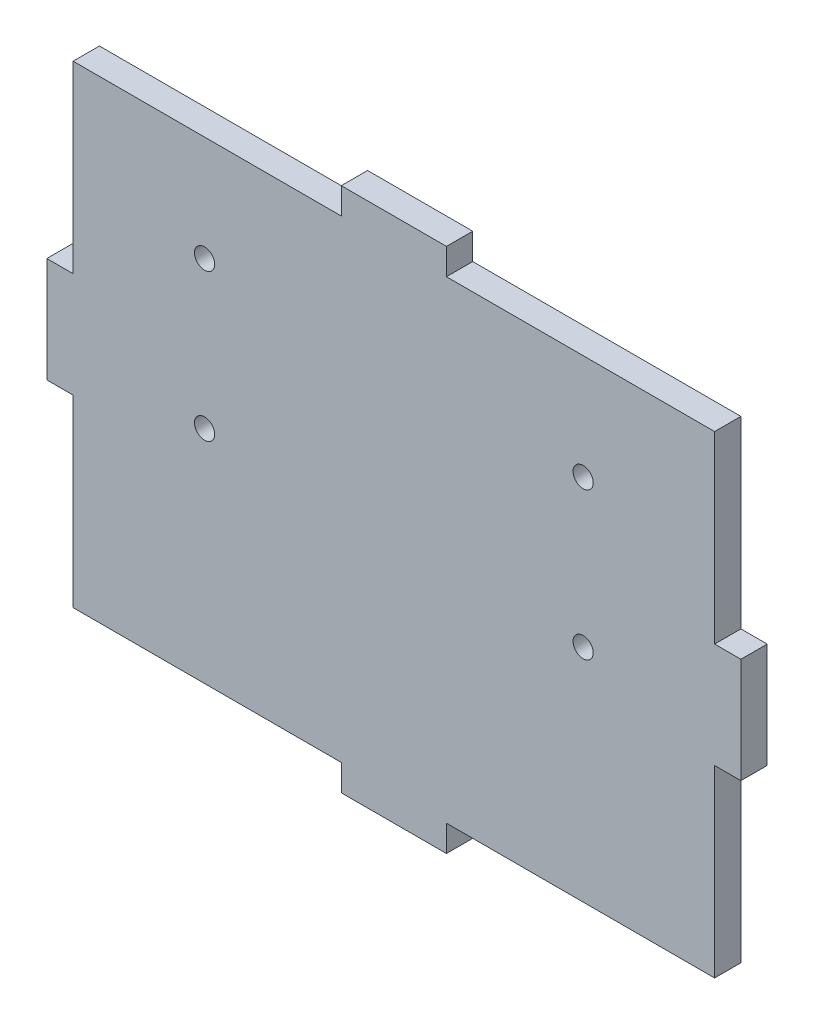
from build123d import *

# Parameters (mm, degrees)
BOSS_EXTRUDE1_DEPTH = 3.175
SKETCH2_R           = 1.2192
CUT_EXTRUDE1_DEPTH  = 4.175


with BuildPart() as part:
    # Sketch1 → Boss-Extrude1 (new body)
    with BuildSketch(Plane.XY):
        Polygon((-38.735, 6.35), (-41.91, 6.35), (-41.91, -6.35), (-38.735, -6.35), (-38.735, -28.575), (-6.35, -28.575), (-6.35, -31.75), (6.35, -31.75), (6.35, -28.575), (38.735, -28.575), (38.735, -6.35), (41.91, -6.35), (41.91, 6.35), (38.735, 6.35), (38.735, 28.575), (6.35, 28.575), (6.35, 31.75), (-6.35, 31.75), (-6.35, 28.575), (-38.735, 28.575), align=None)
    extrude(amount=BOSS_EXTRUDE1_DEPTH)

    # Sketch2 → Cut-Extrude1 (cut, through all)
    with BuildSketch(Plane.XY.offset(3.175)):
        with Locations((-22.86, 15.875)):
            Circle(SKETCH2_R)
        with Locations((22.86, 15.875)):
            Circle(SKETCH2_R)
        with Locations((22.86, -1.905)):
            Circle(SKETCH2_R)
        with Locations((-22.86, -1.905)):
            Circle(SKETCH2_R)
    extrude(amount=-CUT_EXTRUDE1_DEPTH, mode=Mode.SUBTRACT)


solid = part.part
